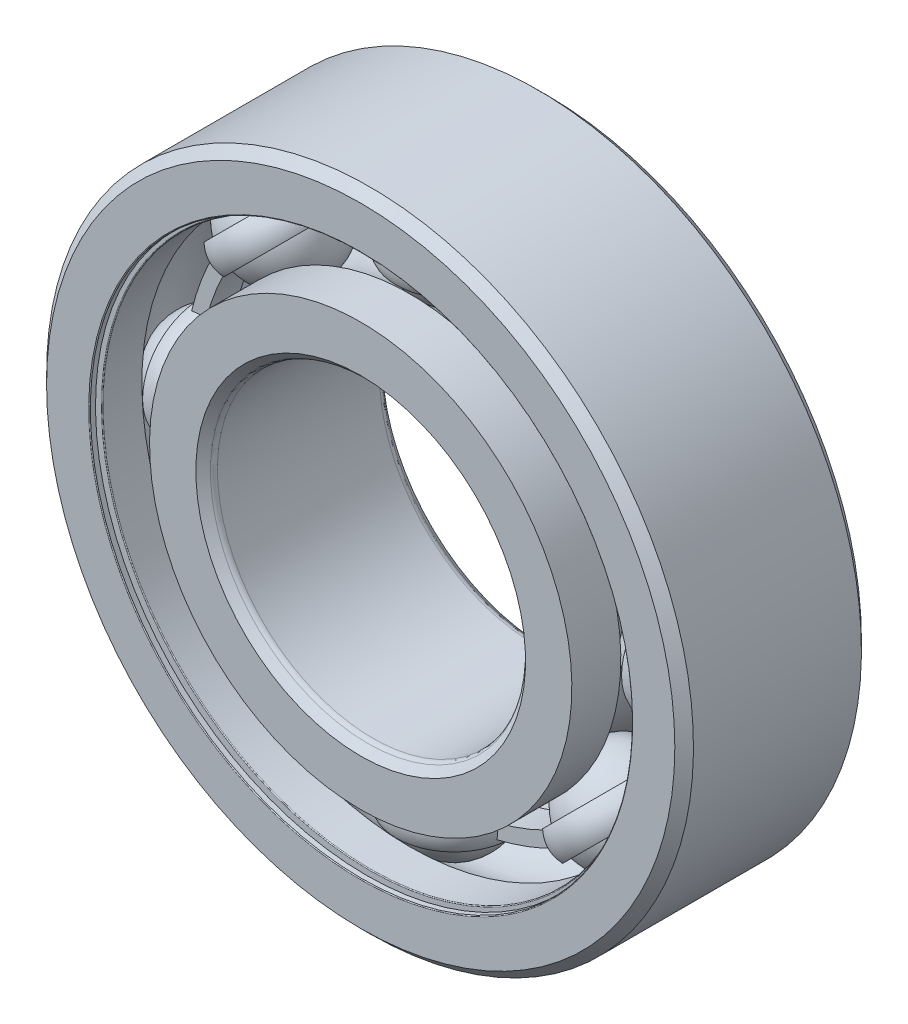
from build123d import *

# Parameters (mm, degrees)
BOSS_EXTRUDE1_DEPTH = 1.25
CIRPATTERN1_COUNT   = 8
CIRPATTERN2_COUNT   = 8
FILLET1_R           = 0.0675
FILLET2_R           = 0.5625


with BuildPart() as part:
    # Sketch3 → Revolve1 (revolve)
    with BuildSketch(Plane(origin=(0, 0, 0), x_dir=(0, 0, -1), z_dir=(1, 0, 0))):
        with BuildLine():
            Line((6.75, 26), (7.5, 25.25))
            Line((7.5, 25.25), (7.5, 21.526923077))
            Line((7.5, 21.526923077), (3.5625, 21.526923077))
            ThreePointArc((3.5625, 21.526923077), (0, 23.47797646), (-3.5625, 21.526923077))
            Line((-3.5625, 21.526923077), (-7.5, 21.526923077))
            Line((-7.5, 21.526923077), (-7.5, 25.25))
            Line((-7.5, 25.25), (-6.75, 26))
            Line((-6.75, 26), (6.75, 26))
        make_face()
    revolve(axis=Axis((0, 0, 7.5), (0, 0, -1)))

    # Sketch8 → Cut-Revolve1 (revolve, cut)
    with BuildSketch(Plane(origin=(0, 0, 0), x_dir=(0, 0, -1), z_dir=(1, 0, 0))):
        Polygon((-7.02, 21.526923077), (-6.75, 21.526923077), (-6.75, 23.017948718), (-7.02, 23.017948718), (-7.02, 21.796923077), (-7.5, 21.796923077), (-7.5, 21.526923077), align=None)
        Polygon((6.75, 21.526923077), (7.02, 21.526923077), (7.5, 21.526923077), (7.5, 21.796923077), (7.02, 21.796923077), (7.02, 23.017948718), (6.75, 23.017948718), align=None)
    revolve(axis=Axis((0, 0, 7.5), (0, 0, -1)), mode=Mode.SUBTRACT)

    # Fillet1
    fillet1_edges = [part.edges().sort_by_distance(p)[0] for p in [
        (0, -21.526923077, -6.75),
        (0, -21.796923077, -7.5),
        (0, -21.526923077, 6.75),
        (0, -21.796923077, 7.5),
    ]]
    fillet(fillet1_edges, radius=FILLET1_R)


with BuildPart() as body_2:
    # Sketch4 → Revolve2 (revolve)
    with BuildSketch(Plane(origin=(0, 0, 0), x_dir=(0, 0, -1), z_dir=(1, 0, 0))):
        with BuildLine():
            Line((-6.75, 12.5), (-7.5, 13.25))
            Line((-7.5, 13.25), (-7.5, 16.973076923))
            Line((-7.5, 16.973076923), (-3.5625, 16.973076923))
            ThreePointArc((-3.5625, 16.973076923), (0, 15.02202354), (3.5625, 16.973076923))
            Line((3.5625, 16.973076923), (7.5, 16.973076923))
            Line((7.5, 16.973076923), (7.5, 13.25))
            Line((7.5, 13.25), (6.75, 12.5))
            Line((6.75, 12.5), (-6.75, 12.5))
        make_face()
    revolve(axis=Axis((0, 0, 7.5), (0, 0, -1)))

    # Fillet2
    fillet2_edges = [body_2.edges().sort_by_distance(p)[0] for p in [
        (0, -12.5, -6.75),
        (0, -12.5, 6.75),
    ]]
    fillet(fillet2_edges, radius=FILLET2_R)


with BuildPart() as body_3:
    # Sketch5 → Revolve3 (revolve)
    with BuildSketch(Plane(origin=(0, 0, 0), x_dir=(0, 0, -1), z_dir=(1, 0, 0))):
        with BuildLine():
            Line((-4.22797646, 19.25), (4.22797646, 19.25))
            ThreePointArc((4.22797646, 19.25), (0, 23.47797646), (-4.22797646, 19.25))
        make_face()
    revolve(axis=Axis((0, 19.25, 4.22797646), (0, 0, -1)))


with BuildPart() as body_4:
    # Sketch6 → Revolve4 (revolve)
    with BuildSketch(Plane(origin=(0, 0, 0), x_dir=(0, 0, -1), z_dir=(1, 0, 0))):
        with BuildLine():
            Line((-4.071816582, 20.388461538), (-4.643180485, 20.388461538))
            ThreePointArc((-4.643180485, 20.388461538), (-4.928862436, 19.25), (-4.643180485, 18.111538462))
            Line((-4.643180485, 18.111538462), (-4.071816582, 18.111538462))
            ThreePointArc((-4.071816582, 18.111538462), (-4.22797646, 19.25), (-4.071816582, 20.388461538))
        make_face()
    revolve4 = revolve(axis=Axis((0, 26, 0), (0, -1, 0)))

    # Sketch7 → Boss-Extrude1 (add, symmetric)
    with BuildSketch(Plane.XY):
        with BuildLine():
            Line((13.983241674, 13.229945286), (14.810222601, 14.012375617))
            ThreePointArc((14.810222601, 14.012375617), (8.062213796, 18.726720819), (0, 20.388461538))
            Line((0, 20.388461538), (0, 19.25))
            ThreePointArc((0, 19.25), (7.612031701, 17.681048424), (13.983241674, 13.229945286))
        make_face()
    boss_extrude1 = extrude(amount=BOSS_EXTRUDE1_DEPTH, both=True)

    # CirPattern2: Revolve4, Boss-Extrude1 ×8 about axis
    cirpattern2_axis = Axis((0, 0, 7.5), (0, 0, -1))
    add([revolve4.rotate(cirpattern2_axis, i * 360 / CIRPATTERN2_COUNT) for i in range(1, CIRPATTERN2_COUNT)])
    add([boss_extrude1.rotate(cirpattern2_axis, i * 360 / CIRPATTERN2_COUNT) for i in range(1, CIRPATTERN2_COUNT)])


with BuildPart() as cirpattern1_1:
    # CirPattern1: pattern copy
    add(body_3.part.rotate(Axis((0, 0, 7.5), (0, 0, -1)), 1 * 360 / CIRPATTERN1_COUNT))


with BuildPart() as cirpattern1_2:
    # CirPattern1: pattern copy
    add(body_3.part.rotate(Axis((0, 0, 7.5), (0, 0, -1)), 2 * 360 / CIRPATTERN1_COUNT))


with BuildPart() as cirpattern1_3:
    # CirPattern1: pattern copy
    add(body_3.part.rotate(Axis((0, 0, 7.5), (0, 0, -1)), 3 * 360 / CIRPATTERN1_COUNT))


with BuildPart() as cirpattern1_4:
    # CirPattern1: pattern copy
    add(body_3.part.rotate(Axis((0, 0, 7.5), (0, 0, -1)), 4 * 360 / CIRPATTERN1_COUNT))


with BuildPart() as cirpattern1_5:
    # CirPattern1: pattern copy
    add(body_3.part.rotate(Axis((0, 0, 7.5), (0, 0, -1)), 5 * 360 / CIRPATTERN1_COUNT))


with BuildPart() as cirpattern1_6:
    # CirPattern1: pattern copy
    add(body_3.part.rotate(Axis((0, 0, 7.5), (0, 0, -1)), 6 * 360 / CIRPATTERN1_COUNT))


with BuildPart() as cirpattern1_7:
    # CirPattern1: pattern copy
    add(body_3.part.rotate(Axis((0, 0, 7.5), (0, 0, -1)), 7 * 360 / CIRPATTERN1_COUNT))


solid = Compound([part.part, body_2.part, body_3.part, body_4.part, cirpattern1_1.part, cirpattern1_2.part, cirpattern1_3.part, cirpattern1_4.part, cirpattern1_5.part, cirpattern1_6.part, cirpattern1_7.part])
